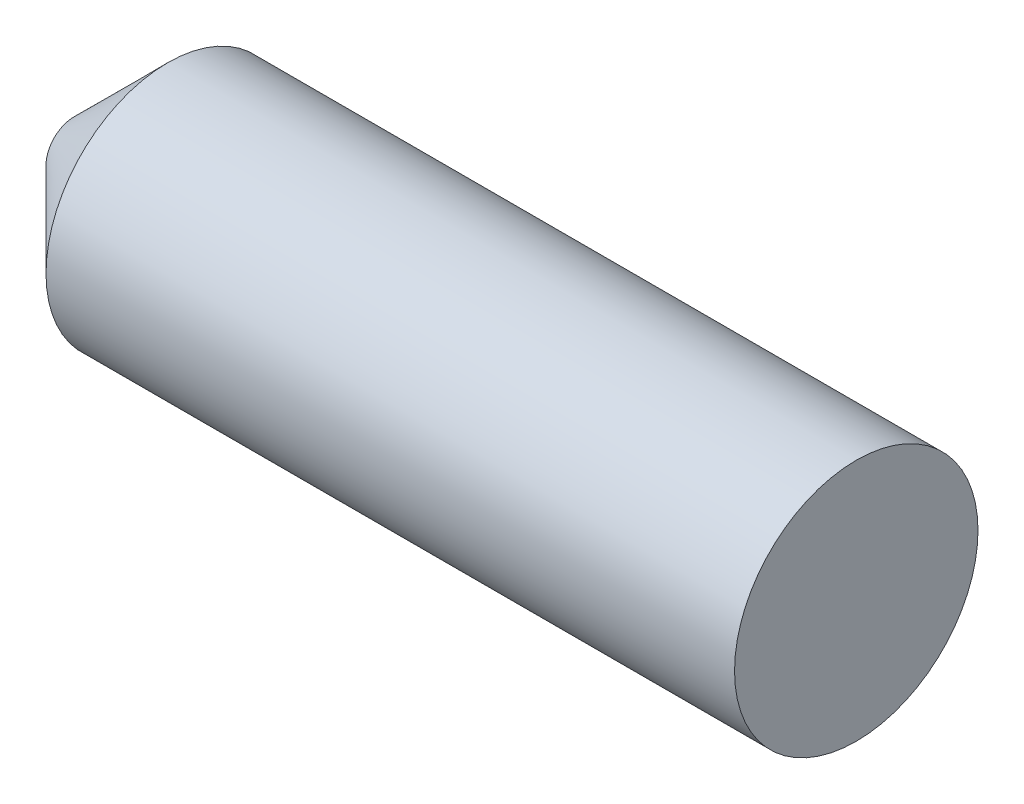
from build123d import *

# Parameters (mm, degrees)
SKETCH1_R           = 24.765
BOSS_EXTRUDE1_DEPTH = 121.031
SKETCH3_R           = 24.765
BOSS_EXTRUDE2_DEPTH = 38.1
CHAMFER1_SIZE       = 19.05


with BuildPart() as part:
    # Sketch1 → Boss-Extrude1 (new body)
    with BuildSketch(Plane(origin=(0, 0, 0), x_dir=(0, 0, -1), z_dir=(1, 0, 0))):
        Circle(SKETCH1_R)
    extrude(amount=BOSS_EXTRUDE1_DEPTH)

    # Sketch3 → Boss-Extrude2 (add)
    with BuildSketch(Plane.ZY):
        Circle(SKETCH3_R)
    extrude(amount=BOSS_EXTRUDE2_DEPTH)

    # Chamfer1
    chamfer1_edges = [part.edges().sort_by_distance(p)[0] for p in [
        (-38.1, 0, -24.765),
    ]]
    chamfer(chamfer1_edges, length=CHAMFER1_SIZE)


solid = part.part
